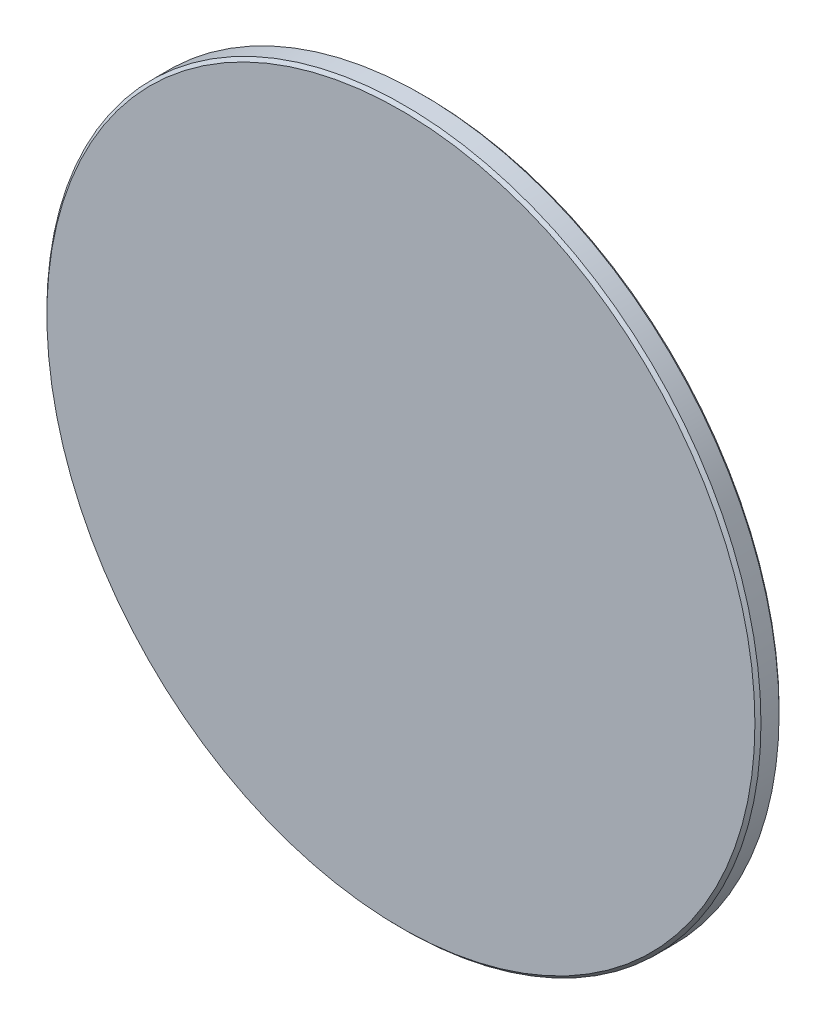
from build123d import *

# Parameters (mm, degrees)
SKETCH_1_R      = 59
EXTRUDE_1_DEPTH = 4
CHAMFER_1_SIZE  = 0.5


with BuildPart() as part:
    # 草图1 → 凸台-拉伸1 (new body)
    with BuildSketch(Plane.XY):
        Circle(SKETCH_1_R)
    extrude(amount=EXTRUDE_1_DEPTH)

    # 倒角1
    chamfer_1_edges = [part.edges().sort_by_distance(p)[0] for p in [
        (-59, 0, 0),
        (-59, 0, 4),
    ]]
    chamfer(chamfer_1_edges, length=CHAMFER_1_SIZE)


solid = part.part
